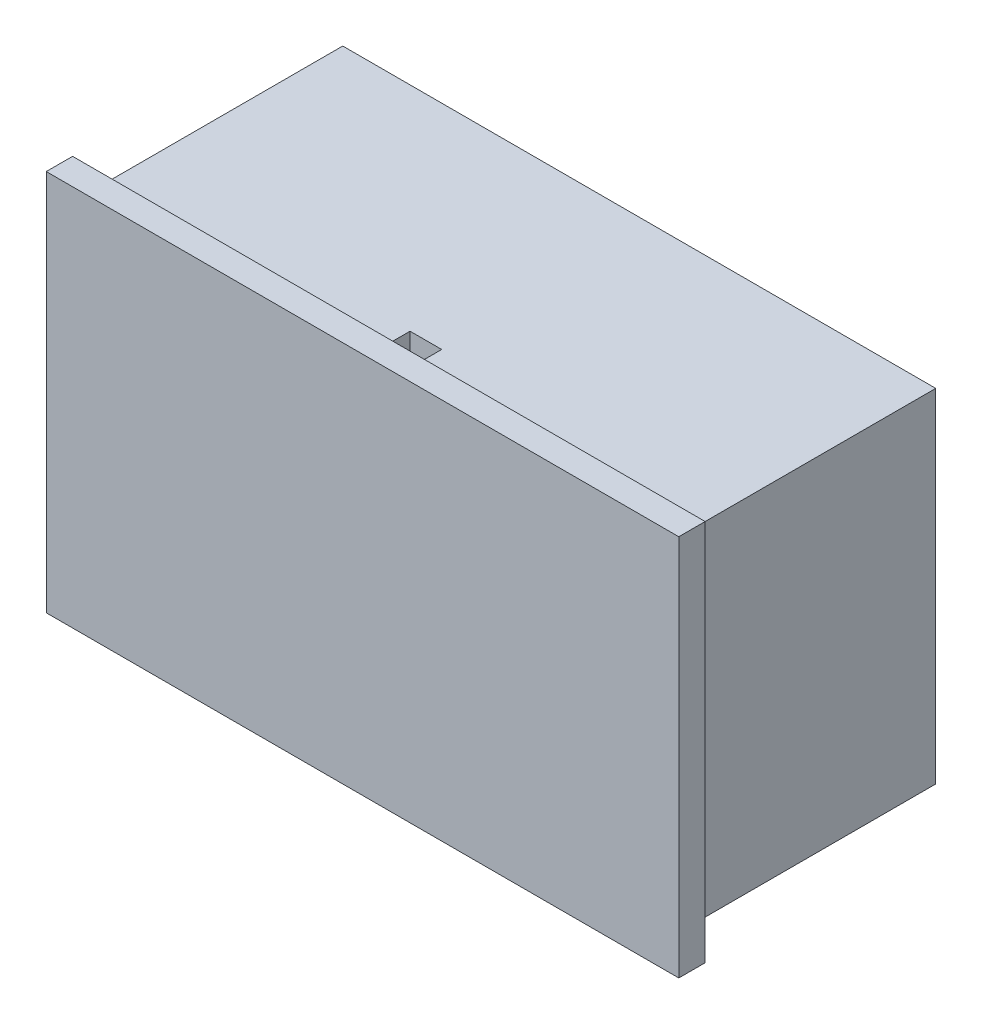
from build123d import *

# Parameters (mm, degrees)
SKETCH1_W           = 45
SKETCH1_H           = 19
BOSS_EXTRUDE1_DEPTH = 26
SKETCH2_W           = 48
SKETCH2_H           = 29
BOSS_EXTRUDE2_DEPTH = 2
SKETCH3_W           = 2.4
SKETCH3_H           = 1.6
CUT_EXTRUDE1_DEPTH  = 2


with BuildPart() as part:
    # Sketch1 → Boss-Extrude1 (new body)
    with BuildSketch(Plane(origin=(0, 0, 0), x_dir=(1, 0, 0), z_dir=(0, 1, 0))):
        Rectangle(SKETCH1_W, SKETCH1_H)
    extrude(amount=BOSS_EXTRUDE1_DEPTH)

    # Sketch2 → Boss-Extrude2 (add)
    with BuildSketch(Plane.XY.offset(9.5)):
        with Locations((0, 13)):
            Rectangle(SKETCH2_W, SKETCH2_H)
    extrude(amount=BOSS_EXTRUDE2_DEPTH)

    # Sketch3 → Cut-Extrude1 (cut)
    with BuildSketch(Plane(origin=(0, 26, 0), x_dir=(1, 0, 0), z_dir=(0, 1, 0))):
        with Locations((-0.003209451, -7.489007977)):
            Rectangle(SKETCH3_W, SKETCH3_H)
    extrude(amount=-CUT_EXTRUDE1_DEPTH, mode=Mode.SUBTRACT)


solid = part.part
